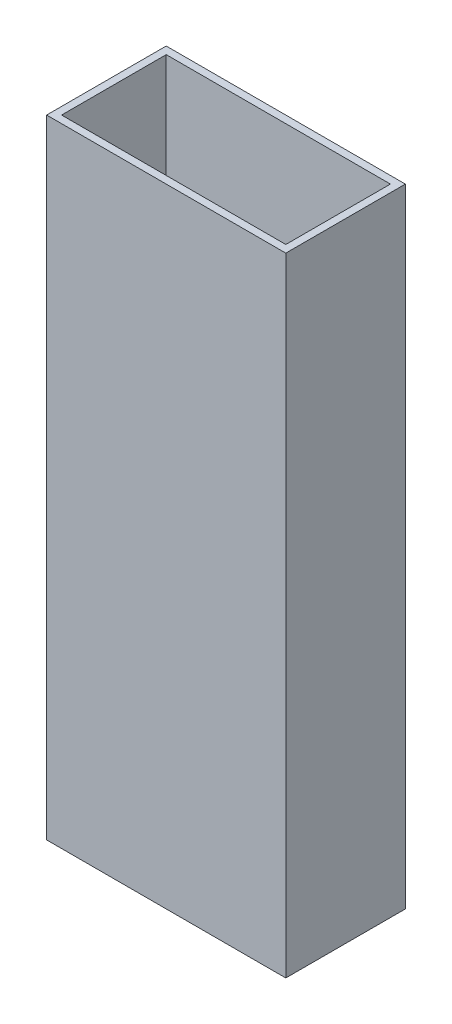
from build123d import *

# Parameters (mm, degrees)
SKETCH1_W           = 50.8
SKETCH1_H           = 25.4
SKETCH1_W_2         = 47.625
SKETCH1_H_2         = 22.225
BOSS_EXTRUDE1_DEPTH = 133.35


with BuildPart() as part:
    # Sketch1 → Boss-Extrude1 (new body)
    with BuildSketch(Plane(origin=(0, 0, 0), x_dir=(1, 0, 0), z_dir=(0, 1, 0))):
        with Locations((6.980152672, -0.19389313)):
            Rectangle(SKETCH1_W, SKETCH1_H)
        with Locations((6.980152672, -0.19389313)):
            Rectangle(SKETCH1_W_2, SKETCH1_H_2, mode=Mode.SUBTRACT)
    extrude(amount=BOSS_EXTRUDE1_DEPTH)


solid = part.part
